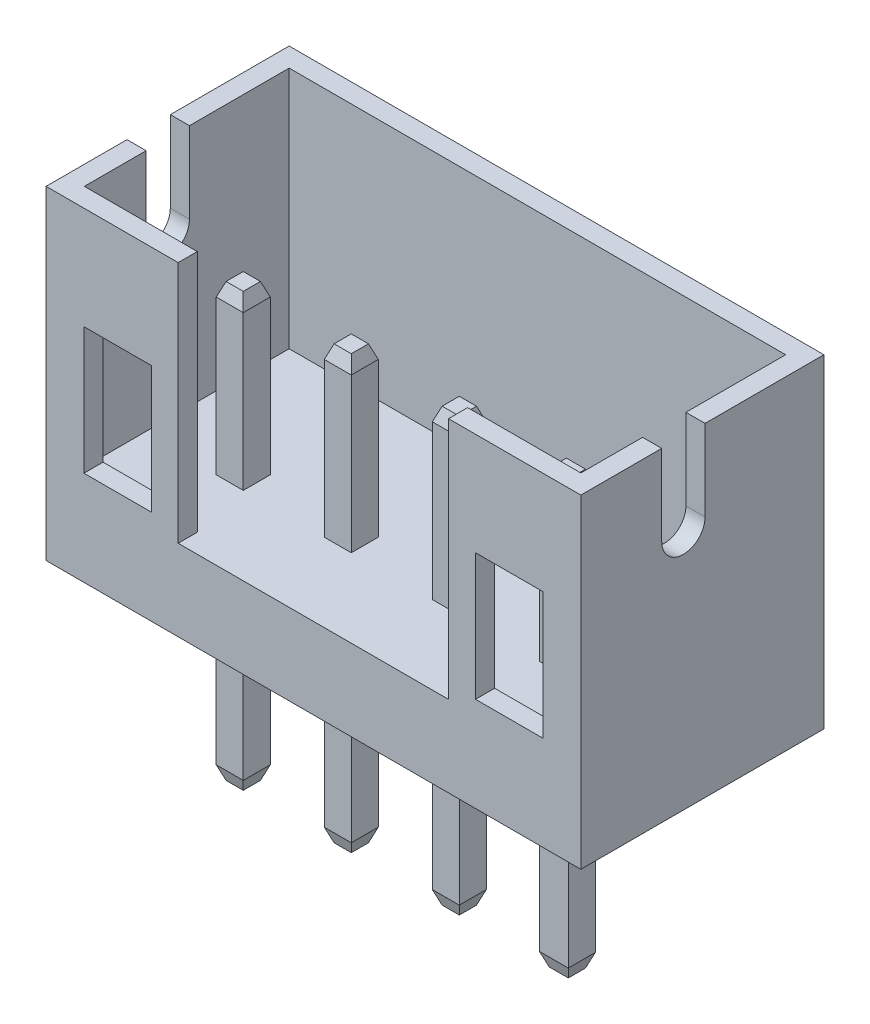
from build123d import *

# Parameters (mm, degrees)
SKETCH1_W              = 9.9
SKETCH1_H              = 6
BOSS_EXTRUDE1_DEPTH    = 4.5
SKETCH2_W              = 9.191478786
SKETCH2_H              = 3.791478786
CUT_EXTRUDE1_DEPTH     = 4.5
SKETCH3_W              = 5.004949596
SKETCH3_H              = 0.354260607
CUT_EXTRUDE2_DEPTH     = 4.5
CUT_EXTRUDE3_DEPTH     = 0.5
SKETCH6_W              = 1.25
SKETCH6_H              = 2.35
CUT_EXTRUDE4_DEPTH     = 0.5
BOSS_EXTRUDE3_START    = -3.4
SKETCH10_W             = 0.5
SKETCH10_H             = 0.5
SKETCH10_W_2           = 0.535638506
BOSS_EXTRUDE3_DEPTH    = 8
CHAMFER1_SIZE          = 0.25
CHAMFER1_SIZE2         = 0.090992559
CHAMFER1_PART_2_SIZE   = 0.25
CHAMFER1_PART_2_SIZE2  = 0.090992559
CHAMFER1_PART_3_SIZE   = 0.25
CHAMFER1_PART_3_SIZE2  = 0.090992559
CHAMFER1_PART_4_SIZE   = 0.25
CHAMFER1_PART_4_SIZE2  = 0.090992559
CHAMFER2_SIZE          = 0.25
CHAMFER2_SIZE2         = 0.090992559
CHAMFER2_PART_2_SIZE   = 0.25
CHAMFER2_PART_2_SIZE2  = 0.090992559
CHAMFER2_PART_3_SIZE   = 0.25
CHAMFER2_PART_3_SIZE2  = 0.090992559
CHAMFER2_PART_4_SIZE   = 0.25
CHAMFER2_PART_4_SIZE2  = 0.090992559
CHAMFER2_PART_5_SIZE   = 0.25
CHAMFER2_PART_5_SIZE2  = 0.090992559
CHAMFER2_PART_6_SIZE   = 0.25
CHAMFER2_PART_6_SIZE2  = 0.090992559
CHAMFER2_PART_7_SIZE   = 0.25
CHAMFER2_PART_7_SIZE2  = 0.090992559
CHAMFER2_PART_8_SIZE   = 0.25
CHAMFER2_PART_8_SIZE2  = 0.090992559
CHAMFER2_PART_9_SIZE   = 0.25
CHAMFER2_PART_9_SIZE2  = 0.090992559
CHAMFER2_PART_10_SIZE  = 0.25
CHAMFER2_PART_10_SIZE2 = 0.090992559
CHAMFER2_PART_11_SIZE  = 0.25
CHAMFER2_PART_11_SIZE2 = 0.090992559
CHAMFER2_PART_12_SIZE  = 0.25
CHAMFER2_PART_12_SIZE2 = 0.090992559
CHAMFER3_SIZE          = 0.25
CHAMFER3_SIZE2         = 0.090992559
CHAMFER3_PART_2_SIZE   = 0.25
CHAMFER3_PART_2_SIZE2  = 0.090992559
CHAMFER3_PART_3_SIZE   = 0.25
CHAMFER3_PART_3_SIZE2  = 0.090992559
CHAMFER3_PART_4_SIZE   = 0.25
CHAMFER3_PART_4_SIZE2  = 0.090992559
CHAMFER3_PART_5_SIZE   = 0.25
CHAMFER3_PART_5_SIZE2  = 0.090992559
CHAMFER3_PART_6_SIZE   = 0.25
CHAMFER3_PART_6_SIZE2  = 0.090992559
CHAMFER3_PART_7_SIZE   = 0.25
CHAMFER3_PART_7_SIZE2  = 0.090992559
CHAMFER3_PART_8_SIZE   = 0.25
CHAMFER3_PART_8_SIZE2  = 0.090992559
CHAMFER3_PART_9_SIZE   = 0.25
CHAMFER3_PART_9_SIZE2  = 0.090992559
CHAMFER3_PART_10_SIZE  = 0.25
CHAMFER3_PART_10_SIZE2 = 0.090992559
CHAMFER3_PART_11_SIZE  = 0.25
CHAMFER3_PART_11_SIZE2 = 0.090992559
CHAMFER3_PART_12_SIZE  = 0.25
CHAMFER3_PART_12_SIZE2 = 0.090992559
CHAMFER3_PART_13_SIZE  = 0.25
CHAMFER3_PART_13_SIZE2 = 0.090992559
CHAMFER3_PART_14_SIZE  = 0.25
CHAMFER3_PART_14_SIZE2 = 0.090992559
CHAMFER3_PART_15_SIZE  = 0.25
CHAMFER3_PART_15_SIZE2 = 0.090992559
CHAMFER3_PART_16_SIZE  = 0.25
CHAMFER3_PART_16_SIZE2 = 0.090992559


with BuildPart() as part:
    # Sketch1 → Boss-Extrude1 (new body)
    with BuildSketch(Plane.XY):
        with Locations((4.95, 3)):
            Rectangle(SKETCH1_W, SKETCH1_H)
    extrude(amount=-BOSS_EXTRUDE1_DEPTH)

    # Sketch2 → Cut-Extrude1 (cut)
    with BuildSketch(Plane(origin=(0, 6, 0), x_dir=(1, 0, 0), z_dir=(0, 1, 0))):
        with Locations((4.95, 2.25)):
            Rectangle(SKETCH2_W, SKETCH2_H)
    extrude(amount=-CUT_EXTRUDE1_DEPTH, mode=Mode.SUBTRACT)

    # Sketch3 → Cut-Extrude2 (cut)
    with BuildSketch(Plane(origin=(0, 1.5, 0), x_dir=(1, 0, 0), z_dir=(0, 1, 0))):
        with Locations((4.947525202, 0.177130304)):
            Rectangle(SKETCH3_W, SKETCH3_H)
    extrude(amount=CUT_EXTRUDE2_DEPTH, mode=Mode.SUBTRACT)

    # Sketch5 → Cut-Extrude3 (cut)
    with BuildSketch(Plane(origin=(9.9, 0, 0), x_dir=(0, 0, -1), z_dir=(1, 0, 0))):
        with BuildLine():
            Line((2.299478677, 6), (1.497924103, 6))
            Line((1.497924103, 6), (1.497924103, 4.5))
            ThreePointArc((1.497924103, 4.5), (1.89870139, 4.900777287), (2.299478677, 4.5))
            Line((2.299478677, 4.5), (2.299478677, 6))
        make_face()
        with BuildLine():
            ThreePointArc((2.299478677, 4.5), (1.89870139, 4.900777287), (1.497924103, 4.5))
            Line((1.497924103, 4.5), (2.299478677, 4.5))
        make_face()
        with BuildLine():
            Line((2.299478677, 4.5), (1.497924103, 4.5))
            ThreePointArc((1.497924103, 4.5), (1.89870139, 4.099222713), (2.299478677, 4.5))
        make_face()
    cut_extrude3 = extrude(amount=-CUT_EXTRUDE3_DEPTH, mode=Mode.SUBTRACT)

    # Mirror1: Cut-Extrude3 across plane
    add(cut_extrude3.mirror(Plane(origin=(4.95, 0, 0), x_dir=(0, 0, 1), z_dir=(1, 0, 0))), mode=Mode.SUBTRACT)

    # Sketch6 → Cut-Extrude4 (cut)
    with BuildSketch(Plane.XY):
        with Locations((1.325196701, 2.925654718)):
            Rectangle(SKETCH6_W, SKETCH6_H)
        with Locations((8.575, 2.925654718)):
            Rectangle(SKETCH6_W, SKETCH6_H)
    extrude(amount=-CUT_EXTRUDE4_DEPTH, mode=Mode.SUBTRACT)

    # Sketch10 → Boss-Extrude3 (add)
    with BuildSketch(Plane(origin=(0, 0, 0), x_dir=(1, 0, 0), z_dir=(0, 1, 0)).offset(BOSS_EXTRUDE3_START)):
        with Locations((1.95, 1.7)):
            Rectangle(SKETCH10_W, SKETCH10_H)
        with Locations((3.95, 1.7)):
            Rectangle(SKETCH10_W, SKETCH10_H)
        with Locations((5.95, 1.7)):
            Rectangle(SKETCH10_W, SKETCH10_H)
        with Locations((7.95, 1.7)):
            Rectangle(SKETCH10_W_2, SKETCH10_H)
    extrude(amount=BOSS_EXTRUDE3_DEPTH)

    # Chamfer1
    chamfer1_edges = [part.edges().sort_by_distance(p)[0] for p in [
        (2.2, 4.6, -1.7),
    ]]
    chamfer1_side = [part.faces().sort_by_distance(p)[0] for p in [
        (2.2, 3.05, -1.7),
    ]]
    chamfer(chamfer1_edges, length=CHAMFER1_SIZE, length2=CHAMFER1_SIZE2, reference=chamfer1_side[0])

    # Chamfer1 part 2
    chamfer1_part_2_edges = [part.edges().sort_by_distance(p)[0] for p in [
        (1.95, 4.6, -1.95),
    ]]
    chamfer1_part_2_side = [part.faces().sort_by_distance(p)[0] for p in [
        (1.95, 3.05, -1.95),
    ]]
    chamfer(chamfer1_part_2_edges, length=CHAMFER1_PART_2_SIZE, length2=CHAMFER1_PART_2_SIZE2, reference=chamfer1_part_2_side[0])

    # Chamfer1 part 3
    chamfer1_part_3_edges = [part.edges().sort_by_distance(p)[0] for p in [
        (1.7, 4.6, -1.7),
    ]]
    chamfer1_part_3_side = [part.faces().sort_by_distance(p)[0] for p in [
        (1.7, 3.05, -1.7),
    ]]
    chamfer(chamfer1_part_3_edges, length=CHAMFER1_PART_3_SIZE, length2=CHAMFER1_PART_3_SIZE2, reference=chamfer1_part_3_side[0])

    # Chamfer1 part 4
    chamfer1_part_4_edges = [part.edges().sort_by_distance(p)[0] for p in [
        (1.95, 4.6, -1.45),
    ]]
    chamfer1_part_4_side = [part.faces().sort_by_distance(p)[0] for p in [
        (1.95, 3.05, -1.45),
    ]]
    chamfer(chamfer1_part_4_edges, length=CHAMFER1_PART_4_SIZE, length2=CHAMFER1_PART_4_SIZE2, reference=chamfer1_part_4_side[0])

    # Chamfer2
    chamfer2_edges = [part.edges().sort_by_distance(p)[0] for p in [
        (4.2, 4.6, -1.7),
    ]]
    chamfer2_side = [part.faces().sort_by_distance(p)[0] for p in [
        (4.2, 3.05, -1.7),
    ]]
    chamfer(chamfer2_edges, length=CHAMFER2_SIZE, length2=CHAMFER2_SIZE2, reference=chamfer2_side[0])

    # Chamfer2 part 2
    chamfer2_part_2_edges = [part.edges().sort_by_distance(p)[0] for p in [
        (3.95, 4.6, -1.95),
    ]]
    chamfer2_part_2_side = [part.faces().sort_by_distance(p)[0] for p in [
        (3.95, 3.05, -1.95),
    ]]
    chamfer(chamfer2_part_2_edges, length=CHAMFER2_PART_2_SIZE, length2=CHAMFER2_PART_2_SIZE2, reference=chamfer2_part_2_side[0])

    # Chamfer2 part 3
    chamfer2_part_3_edges = [part.edges().sort_by_distance(p)[0] for p in [
        (3.7, 4.6, -1.7),
    ]]
    chamfer2_part_3_side = [part.faces().sort_by_distance(p)[0] for p in [
        (3.7, 3.05, -1.7),
    ]]
    chamfer(chamfer2_part_3_edges, length=CHAMFER2_PART_3_SIZE, length2=CHAMFER2_PART_3_SIZE2, reference=chamfer2_part_3_side[0])

    # Chamfer2 part 4
    chamfer2_part_4_edges = [part.edges().sort_by_distance(p)[0] for p in [
        (3.95, 4.6, -1.45),
    ]]
    chamfer2_part_4_side = [part.faces().sort_by_distance(p)[0] for p in [
        (3.95, 3.05, -1.45),
    ]]
    chamfer(chamfer2_part_4_edges, length=CHAMFER2_PART_4_SIZE, length2=CHAMFER2_PART_4_SIZE2, reference=chamfer2_part_4_side[0])

    # Chamfer2 part 5
    chamfer2_part_5_edges = [part.edges().sort_by_distance(p)[0] for p in [
        (6.2, 4.6, -1.7),
    ]]
    chamfer2_part_5_side = [part.faces().sort_by_distance(p)[0] for p in [
        (6.2, 3.05, -1.7),
    ]]
    chamfer(chamfer2_part_5_edges, length=CHAMFER2_PART_5_SIZE, length2=CHAMFER2_PART_5_SIZE2, reference=chamfer2_part_5_side[0])

    # Chamfer2 part 6
    chamfer2_part_6_edges = [part.edges().sort_by_distance(p)[0] for p in [
        (5.95, 4.6, -1.95),
    ]]
    chamfer2_part_6_side = [part.faces().sort_by_distance(p)[0] for p in [
        (5.95, 3.05, -1.95),
    ]]
    chamfer(chamfer2_part_6_edges, length=CHAMFER2_PART_6_SIZE, length2=CHAMFER2_PART_6_SIZE2, reference=chamfer2_part_6_side[0])

    # Chamfer2 part 7
    chamfer2_part_7_edges = [part.edges().sort_by_distance(p)[0] for p in [
        (5.7, 4.6, -1.7),
    ]]
    chamfer2_part_7_side = [part.faces().sort_by_distance(p)[0] for p in [
        (5.7, 3.05, -1.7),
    ]]
    chamfer(chamfer2_part_7_edges, length=CHAMFER2_PART_7_SIZE, length2=CHAMFER2_PART_7_SIZE2, reference=chamfer2_part_7_side[0])

    # Chamfer2 part 8
    chamfer2_part_8_edges = [part.edges().sort_by_distance(p)[0] for p in [
        (5.95, 4.6, -1.45),
    ]]
    chamfer2_part_8_side = [part.faces().sort_by_distance(p)[0] for p in [
        (5.95, 3.05, -1.45),
    ]]
    chamfer(chamfer2_part_8_edges, length=CHAMFER2_PART_8_SIZE, length2=CHAMFER2_PART_8_SIZE2, reference=chamfer2_part_8_side[0])

    # Chamfer2 part 9
    chamfer2_part_9_edges = [part.edges().sort_by_distance(p)[0] for p in [
        (8.217819253, 4.6, -1.7),
    ]]
    chamfer2_part_9_side = [part.faces().sort_by_distance(p)[0] for p in [
        (8.217819253, 3.05, -1.7),
    ]]
    chamfer(chamfer2_part_9_edges, length=CHAMFER2_PART_9_SIZE, length2=CHAMFER2_PART_9_SIZE2, reference=chamfer2_part_9_side[0])

    # Chamfer2 part 10
    chamfer2_part_10_edges = [part.edges().sort_by_distance(p)[0] for p in [
        (7.95, 4.6, -1.95),
    ]]
    chamfer2_part_10_side = [part.faces().sort_by_distance(p)[0] for p in [
        (7.95, 3.05, -1.95),
    ]]
    chamfer(chamfer2_part_10_edges, length=CHAMFER2_PART_10_SIZE, length2=CHAMFER2_PART_10_SIZE2, reference=chamfer2_part_10_side[0])

    # Chamfer2 part 11
    chamfer2_part_11_edges = [part.edges().sort_by_distance(p)[0] for p in [
        (7.682180747, 4.6, -1.7),
    ]]
    chamfer2_part_11_side = [part.faces().sort_by_distance(p)[0] for p in [
        (7.682180747, 3.05, -1.7),
    ]]
    chamfer(chamfer2_part_11_edges, length=CHAMFER2_PART_11_SIZE, length2=CHAMFER2_PART_11_SIZE2, reference=chamfer2_part_11_side[0])

    # Chamfer2 part 12
    chamfer2_part_12_edges = [part.edges().sort_by_distance(p)[0] for p in [
        (7.95, 4.6, -1.45),
    ]]
    chamfer2_part_12_side = [part.faces().sort_by_distance(p)[0] for p in [
        (7.95, 3.05, -1.45),
    ]]
    chamfer(chamfer2_part_12_edges, length=CHAMFER2_PART_12_SIZE, length2=CHAMFER2_PART_12_SIZE2, reference=chamfer2_part_12_side[0])

    # Chamfer3
    chamfer3_edges = [part.edges().sort_by_distance(p)[0] for p in [
        (2.2, -3.4, -1.7),
    ]]
    chamfer3_side = [part.faces().sort_by_distance(p)[0] for p in [
        (2.2, -1.7, -1.7),
    ]]
    chamfer(chamfer3_edges, length=CHAMFER3_SIZE, length2=CHAMFER3_SIZE2, reference=chamfer3_side[0])

    # Chamfer3 part 2
    chamfer3_part_2_edges = [part.edges().sort_by_distance(p)[0] for p in [
        (1.95, -3.4, -1.95),
    ]]
    chamfer3_part_2_side = [part.faces().sort_by_distance(p)[0] for p in [
        (1.95, -1.7, -1.95),
    ]]
    chamfer(chamfer3_part_2_edges, length=CHAMFER3_PART_2_SIZE, length2=CHAMFER3_PART_2_SIZE2, reference=chamfer3_part_2_side[0])

    # Chamfer3 part 3
    chamfer3_part_3_edges = [part.edges().sort_by_distance(p)[0] for p in [
        (1.7, -3.4, -1.7),
    ]]
    chamfer3_part_3_side = [part.faces().sort_by_distance(p)[0] for p in [
        (1.7, -1.7, -1.7),
    ]]
    chamfer(chamfer3_part_3_edges, length=CHAMFER3_PART_3_SIZE, length2=CHAMFER3_PART_3_SIZE2, reference=chamfer3_part_3_side[0])

    # Chamfer3 part 4
    chamfer3_part_4_edges = [part.edges().sort_by_distance(p)[0] for p in [
        (1.95, -3.4, -1.45),
    ]]
    chamfer3_part_4_side = [part.faces().sort_by_distance(p)[0] for p in [
        (1.95, -1.7, -1.45),
    ]]
    chamfer(chamfer3_part_4_edges, length=CHAMFER3_PART_4_SIZE, length2=CHAMFER3_PART_4_SIZE2, reference=chamfer3_part_4_side[0])

    # Chamfer3 part 5
    chamfer3_part_5_edges = [part.edges().sort_by_distance(p)[0] for p in [
        (4.2, -3.4, -1.7),
    ]]
    chamfer3_part_5_side = [part.faces().sort_by_distance(p)[0] for p in [
        (4.2, -1.7, -1.7),
    ]]
    chamfer(chamfer3_part_5_edges, length=CHAMFER3_PART_5_SIZE, length2=CHAMFER3_PART_5_SIZE2, reference=chamfer3_part_5_side[0])

    # Chamfer3 part 6
    chamfer3_part_6_edges = [part.edges().sort_by_distance(p)[0] for p in [
        (3.95, -3.4, -1.95),
    ]]
    chamfer3_part_6_side = [part.faces().sort_by_distance(p)[0] for p in [
        (3.95, -1.7, -1.95),
    ]]
    chamfer(chamfer3_part_6_edges, length=CHAMFER3_PART_6_SIZE, length2=CHAMFER3_PART_6_SIZE2, reference=chamfer3_part_6_side[0])

    # Chamfer3 part 7
    chamfer3_part_7_edges = [part.edges().sort_by_distance(p)[0] for p in [
        (3.7, -3.4, -1.7),
    ]]
    chamfer3_part_7_side = [part.faces().sort_by_distance(p)[0] for p in [
        (3.7, -1.7, -1.7),
    ]]
    chamfer(chamfer3_part_7_edges, length=CHAMFER3_PART_7_SIZE, length2=CHAMFER3_PART_7_SIZE2, reference=chamfer3_part_7_side[0])

    # Chamfer3 part 8
    chamfer3_part_8_edges = [part.edges().sort_by_distance(p)[0] for p in [
        (3.95, -3.4, -1.45),
    ]]
    chamfer3_part_8_side = [part.faces().sort_by_distance(p)[0] for p in [
        (3.95, -1.7, -1.45),
    ]]
    chamfer(chamfer3_part_8_edges, length=CHAMFER3_PART_8_SIZE, length2=CHAMFER3_PART_8_SIZE2, reference=chamfer3_part_8_side[0])

    # Chamfer3 part 9
    chamfer3_part_9_edges = [part.edges().sort_by_distance(p)[0] for p in [
        (6.2, -3.4, -1.7),
    ]]
    chamfer3_part_9_side = [part.faces().sort_by_distance(p)[0] for p in [
        (6.2, -1.7, -1.7),
    ]]
    chamfer(chamfer3_part_9_edges, length=CHAMFER3_PART_9_SIZE, length2=CHAMFER3_PART_9_SIZE2, reference=chamfer3_part_9_side[0])

    # Chamfer3 part 10
    chamfer3_part_10_edges = [part.edges().sort_by_distance(p)[0] for p in [
        (5.95, -3.4, -1.95),
    ]]
    chamfer3_part_10_side = [part.faces().sort_by_distance(p)[0] for p in [
        (5.95, -1.7, -1.95),
    ]]
    chamfer(chamfer3_part_10_edges, length=CHAMFER3_PART_10_SIZE, length2=CHAMFER3_PART_10_SIZE2, reference=chamfer3_part_10_side[0])

    # Chamfer3 part 11
    chamfer3_part_11_edges = [part.edges().sort_by_distance(p)[0] for p in [
        (5.7, -3.4, -1.7),
    ]]
    chamfer3_part_11_side = [part.faces().sort_by_distance(p)[0] for p in [
        (5.7, -1.7, -1.7),
    ]]
    chamfer(chamfer3_part_11_edges, length=CHAMFER3_PART_11_SIZE, length2=CHAMFER3_PART_11_SIZE2, reference=chamfer3_part_11_side[0])

    # Chamfer3 part 12
    chamfer3_part_12_edges = [part.edges().sort_by_distance(p)[0] for p in [
        (5.95, -3.4, -1.45),
    ]]
    chamfer3_part_12_side = [part.faces().sort_by_distance(p)[0] for p in [
        (5.95, -1.7, -1.45),
    ]]
    chamfer(chamfer3_part_12_edges, length=CHAMFER3_PART_12_SIZE, length2=CHAMFER3_PART_12_SIZE2, reference=chamfer3_part_12_side[0])

    # Chamfer3 part 13
    chamfer3_part_13_edges = [part.edges().sort_by_distance(p)[0] for p in [
        (8.217819253, -3.4, -1.7),
    ]]
    chamfer3_part_13_side = [part.faces().sort_by_distance(p)[0] for p in [
        (8.217819253, -1.7, -1.7),
    ]]
    chamfer(chamfer3_part_13_edges, length=CHAMFER3_PART_13_SIZE, length2=CHAMFER3_PART_13_SIZE2, reference=chamfer3_part_13_side[0])

    # Chamfer3 part 14
    chamfer3_part_14_edges = [part.edges().sort_by_distance(p)[0] for p in [
        (7.95, -3.4, -1.95),
    ]]
    chamfer3_part_14_side = [part.faces().sort_by_distance(p)[0] for p in [
        (7.95, -1.7, -1.95),
    ]]
    chamfer(chamfer3_part_14_edges, length=CHAMFER3_PART_14_SIZE, length2=CHAMFER3_PART_14_SIZE2, reference=chamfer3_part_14_side[0])

    # Chamfer3 part 15
    chamfer3_part_15_edges = [part.edges().sort_by_distance(p)[0] for p in [
        (7.682180747, -3.4, -1.7),
    ]]
    chamfer3_part_15_side = [part.faces().sort_by_distance(p)[0] for p in [
        (7.682180747, -1.7, -1.7),
    ]]
    chamfer(chamfer3_part_15_edges, length=CHAMFER3_PART_15_SIZE, length2=CHAMFER3_PART_15_SIZE2, reference=chamfer3_part_15_side[0])

    # Chamfer3 part 16
    chamfer3_part_16_edges = [part.edges().sort_by_distance(p)[0] for p in [
        (7.95, -3.4, -1.45),
    ]]
    chamfer3_part_16_side = [part.faces().sort_by_distance(p)[0] for p in [
        (7.95, -1.7, -1.45),
    ]]
    chamfer(chamfer3_part_16_edges, length=CHAMFER3_PART_16_SIZE, length2=CHAMFER3_PART_16_SIZE2, reference=chamfer3_part_16_side[0])


solid = part.part
